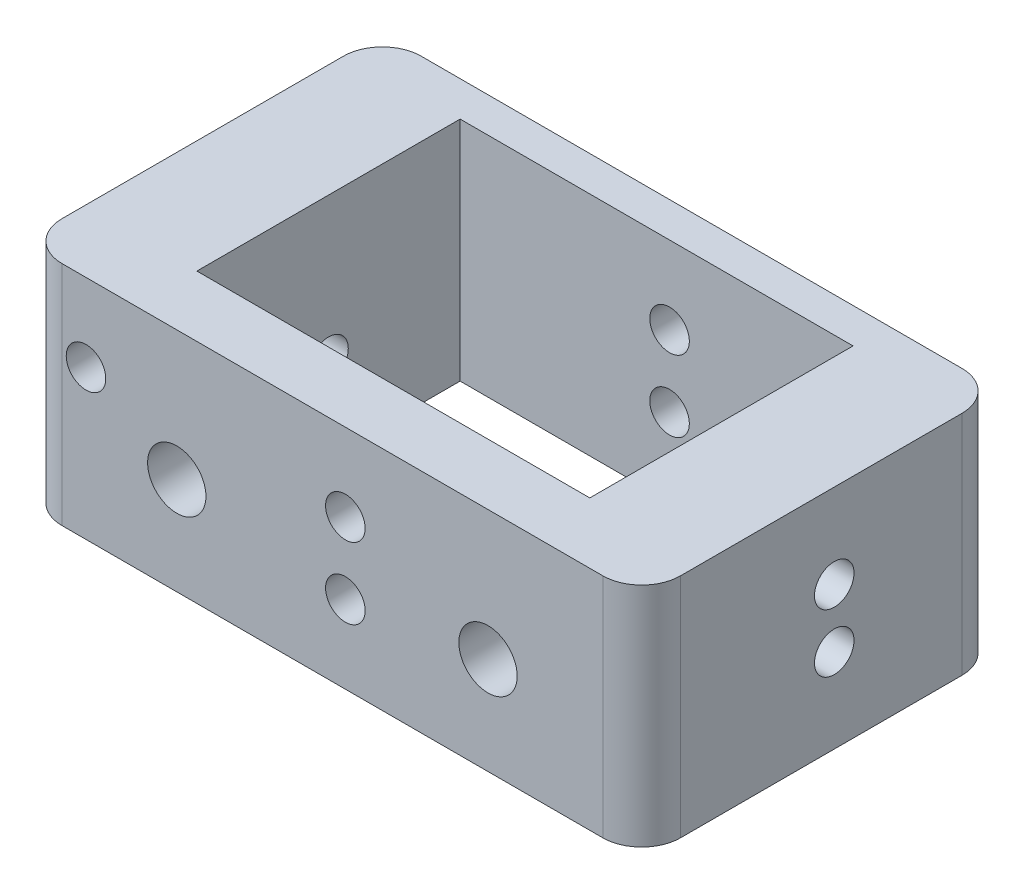
from build123d import *

# Parameters (mm, degrees)
SKETCH_1_W               = 47.7
SKETCH_1_H               = 27.7
SKETCH_1_W_2             = 30.3
SKETCH_1_H_2             = 20.3
EXTRUDE_1_DEPTH          = 8.75
SKETCH_2_R               = 1.525
CUT_EXTRUDE_1_DEPTH      = 28.7
SKETCH_3_R               = 1.525
CUT_EXTRUDE_2_DEPTH      = 48.7
SKETCH_4_R               = 1.525
CUT_EXTRUDE_3_DEPTH      = 28.7
SKETCH_5_R               = 2.25
CUT_EXTRUDE_4_DEPTH      = 5
SKETCH_7_R               = 1.525
CUT_EXTRUDE_6_DEPTH      = 1
CUT_EXTRUDE_6_DEPTH_BACK = 28.7
CUT_EXTRUDE_7_REACH      = 49.7
SKETCH_8_R               = 1.525
FILLET_2_R               = 3


with BuildPart() as part:
    # 草图1 → 凸台-拉伸1 (new body, symmetric)
    with BuildSketch(Plane(origin=(0, 0, 0), x_dir=(1, 0, 0), z_dir=(0, 1, 0))):
        Rectangle(SKETCH_1_W, SKETCH_1_H)
        with Locations((0, 1)):
            Rectangle(SKETCH_1_W_2, SKETCH_1_H_2, mode=Mode.SUBTRACT)
    extrude(amount=EXTRUDE_1_DEPTH, both=True)

    # 草图2 → 切除-拉伸1 (cut, through all)
    with BuildSketch(Plane(origin=(0, 0, -13.85), x_dir=(-1, 0, 0), z_dir=(0, 0, -1))):
        with Locations((-1, 2.75)):
            Circle(SKETCH_2_R)
    extrude(amount=-CUT_EXTRUDE_1_DEPTH, mode=Mode.SUBTRACT)

    # 草图3 → 切除-拉伸2 (cut, through all)
    with BuildSketch(Plane(origin=(23.85, 0, 0), x_dir=(0, 0, -1), z_dir=(1, 0, 0))):
        with Locations((1, -2.25)):
            Circle(SKETCH_3_R)
    extrude(amount=-CUT_EXTRUDE_2_DEPTH, mode=Mode.SUBTRACT)

    # 草图4 → 切除-拉伸3 (cut, through all)
    with BuildSketch(Plane(origin=(0, 0, -13.85), x_dir=(-1, 0, 0), z_dir=(0, 0, -1))):
        with Locations((19, 2.75)):
            Circle(SKETCH_4_R)
    extrude(amount=-CUT_EXTRUDE_3_DEPTH, mode=Mode.SUBTRACT)

    # 草图5 → 切除-拉伸4 (cut)
    with BuildSketch(Plane.XY.offset(13.85)):
        with Locations((-12, -1.25)):
            Circle(SKETCH_5_R)
        with Locations((12, -1.25)):
            Circle(SKETCH_5_R)
    extrude(amount=-CUT_EXTRUDE_4_DEPTH, mode=Mode.SUBTRACT)

    # 草图7 → 切除-拉伸6 (cut, two sides)
    with BuildSketch(Plane(origin=(0, 0, -13.85), x_dir=(-1, 0, 0), z_dir=(0, 0, -1))) as cut_extrude_6_sk:
        with Locations((-1, -2.75)):
            Circle(SKETCH_7_R)
    extrude(amount=CUT_EXTRUDE_6_DEPTH, mode=Mode.SUBTRACT)
    extrude(cut_extrude_6_sk.sketch, amount=-CUT_EXTRUDE_6_DEPTH_BACK, mode=Mode.SUBTRACT)

    # 草图8 → 切除-拉伸7 (cut, up to next)
    with BuildSketch(Plane(origin=(23.85, 0, 0), x_dir=(0, 0, -1), z_dir=(1, 0, 0)), mode=Mode.PRIVATE) as cut_extrude_7_sk1:
        with Locations((1, 2.25)):
            Circle(SKETCH_8_R)
    cut_extrude_7_tool1 = extrude(cut_extrude_7_sk1.sketch, amount=-CUT_EXTRUDE_7_REACH, mode=Mode.PRIVATE) & part.part
    add(cut_extrude_7_tool1.solids().sort_by_distance((23.85, 2.25, -1))[0], mode=Mode.SUBTRACT)

    # 圆角2
    fillet_2_edges = [part.edges().sort_by_distance(p)[0] for p in [
        (23.85, 0, 13.85),
        (-23.85, 0, 13.85),
        (-23.85, 0, -13.85),
        (23.85, 0, -13.85),
    ]]
    fillet(fillet_2_edges, radius=FILLET_2_R)


solid = part.part
